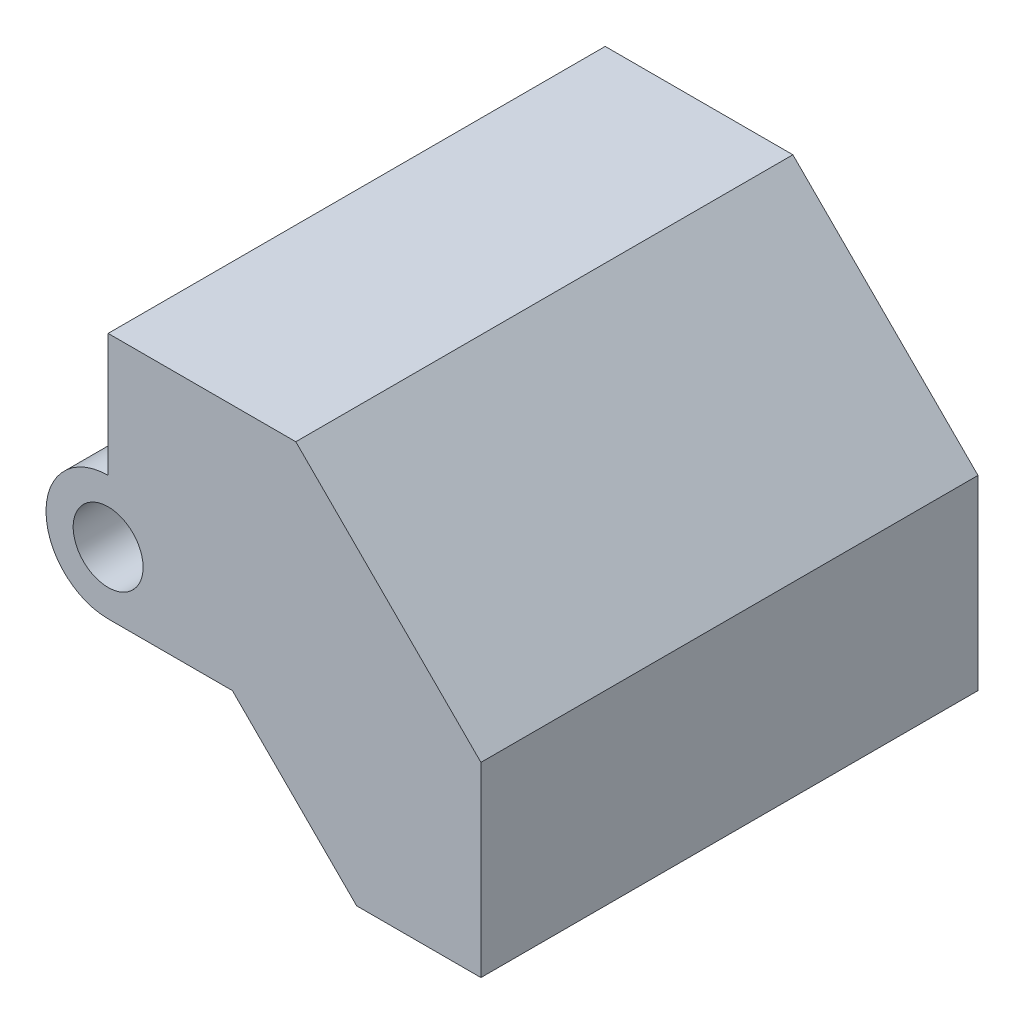
from build123d import *

# Parameters (mm, degrees)
BOSS_EXTRUDE1_DEPTH             = 50.8
F_9_32_0_28125_DIAMETER_HOLE1_D = 7.14375


with BuildPart() as part:
    # Sketch1 → Boss-Extrude1 (new body)
    with BuildSketch(Plane.XY):
        with BuildLine():
            ThreePointArc((0.076969069, 5.862862723), (-1.78290287, 1.372734663), (-6.273030931, -0.487137277))
            Line((-6.273030931, -0.487137277), (6.426969069, -0.487137277))
            Line((6.426969069, -0.487137277), (19.126969069, -13.187137277))
            Line((19.126969069, -13.187137277), (31.826969069, -13.187137277))
            Line((31.826969069, -13.187137277), (31.826969069, 5.862862723))
            Line((31.826969069, 5.862862723), (12.908151542, 24.781680251))
            Line((12.908151542, 24.781680251), (-6.273030931, 24.781680251))
            Line((-6.273030931, 24.781680251), (-6.273030931, 12.212862723))
            ThreePointArc((-6.273030931, 12.212862723), (-1.78290287, 10.352990784), (0.076969069, 5.862862723))
        make_face()
        with BuildLine():
            ThreePointArc((-6.273030931, 12.212862723), (-12.623030931, 5.862862723), (-6.273030931, -0.487137277))
            Line((-6.273030931, -0.487137277), (-6.273030931, 12.212862723))
        make_face()
        with BuildLine():
            Line((-6.273030931, 12.212862723), (-6.273030931, -0.487137277))
            ThreePointArc((-6.273030931, -0.487137277), (-1.78290287, 1.372734663), (0.076969069, 5.862862723))
            ThreePointArc((0.076969069, 5.862862723), (-1.78290287, 10.352990784), (-6.273030931, 12.212862723))
        make_face()
    extrude(amount=-BOSS_EXTRUDE1_DEPTH)

    # 9/32 (0.28125) Diameter Hole1 (through all)
    with Locations(Plane(origin=(-6.273030931, 5.862862723, 0), x_dir=(1, 0, 0), z_dir=(0, 0, 1))):
        with Locations((0, 0)):
            Hole(F_9_32_0_28125_DIAMETER_HOLE1_D / 2)


solid = part.part
